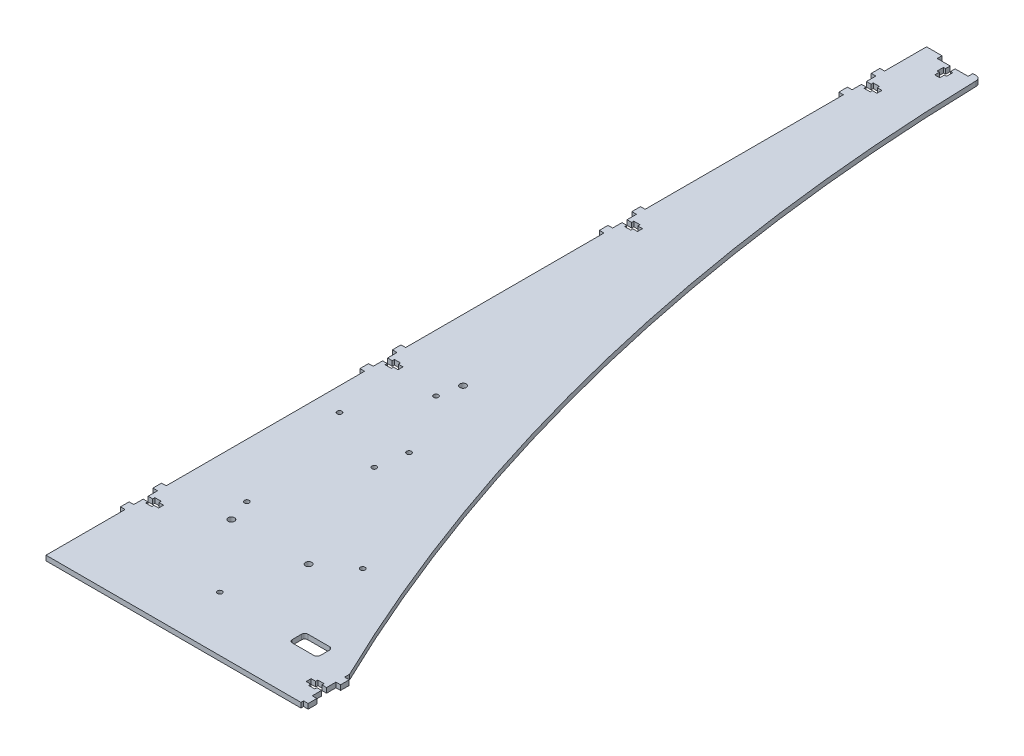
from build123d import *

# Parameters (mm, degrees)
SALIENTE_EXTRUIR1_DEPTH = 3.2
CROQUIS3_R              = 2.05
CORTAR_EXTRUIR2_DEPTH   = 3.2
CORTAR_EXTRUIR3_DEPTH   = 3.2
CORTAR_EXTRUIR4_DEPTH   = 3.2
REDONDEO1_R             = 3
CROQUIS6_R              = 1.55
CORTAR_EXTRUIR5_DEPTH   = 3.2
CROQUIS7_W              = 3
CROQUIS7_H              = 0.2
CORTAR_EXTRUIR6_DEPTH   = 3.2


with BuildPart() as part:
    # Croquis1 → Saliente-Extruir1 (new body)
    with BuildSketch(Plane(origin=(0, 0, 0), x_dir=(1, 0, 0), z_dir=(0, 1, 0))):
        Polygon((7, 66.1), (10, 66.1), (10, 62.9), (7, 62.9), (7, 61.5), (3, 61.5), (3, 62.9), (0, 62.9), (0, 57), (-3, 57), (-3, 51), (0, 51), (0, 0), (165, 0), (165, 1.5), (168, 1.5), (168, 7.5), (165, 7.5), (165, 13.4), (162, 13.4), (162, 12), (158, 12), (158, 13.4), (155, 13.4), (155, 16.6), (158, 16.6), (158, 18), (162, 18), (162, 16.6), (165, 16.6), (165, 22.5), (168, 22.5), (168, 28.5), (165, 28.5), (165, 570), (30, 570), (30, 566.9), (21.6, 566.9), (21.6, 563.9), (23, 563.9), (23, 559.9), (21.6, 559.9), (21.6, 556.9), (18.4, 556.9), (18.4, 559.9), (17, 559.9), (17, 563.9), (18.4, 563.9), (18.4, 566.9), (10, 566.9), (10, 570), (0, 570), (0, 543), (-3, 543), (-3, 537), (0, 537), (0, 531.1), (3, 531.1), (3, 532.5), (7, 532.5), (7, 531.1), (10, 531.1), (10, 527.9), (7, 527.9), (7, 526.5), (3, 526.5), (3, 527.9), (0, 527.9), (0, 522), (-3, 522), (-3, 516), (0, 516), (0, 388), (-3, 388), (-3, 382), (0, 382), (0, 376.1), (3, 376.1), (3, 377.5), (7, 377.5), (7, 376.1), (10, 376.1), (10, 372.9), (7, 372.9), (7, 371.5), (3, 371.5), (3, 372.9), (0, 372.9), (0, 367), (-3, 367), (-3, 361), (0, 361), (0, 233), (-3, 233), (-3, 227), (0, 227), (0, 221.1), (3, 221.1), (3, 222.5), (7, 222.5), (7, 221.1), (10, 221.1), (10, 217.9), (7, 217.9), (7, 216.5), (3, 216.5), (3, 217.9), (0, 217.9), (0, 212), (-3, 212), (-3, 206), (0, 206), (0, 78), (-3, 78), (-3, 72), (0, 72), (0, 66.1), (3, 66.1), (3, 67.5), (7, 67.5), align=None)
    extrude(amount=SALIENTE_EXTRUIR1_DEPTH)

    # Croquis3 → Cortar-Extruir2 (cut)
    with BuildSketch(Plane(origin=(0, 3.2, 0), x_dir=(1, 0, 0), z_dir=(0, 1, 0))):
        with Locations((40, 80)):
            Circle(CROQUIS3_R)
        with Locations((90, 80)):
            Circle(CROQUIS3_R)
        with Locations((40, 230)):
            Circle(CROQUIS3_R)
    extrude(amount=-CORTAR_EXTRUIR2_DEPTH, mode=Mode.SUBTRACT)

    # Croquis4 → Cortar-Extruir3 (cut)
    with BuildSketch(Plane.XZ):
        with BuildLine():
            Line((143, -30.5), (129, -30.5))
            ThreePointArc((129, -30.5), (127.585786438, -31.085786438), (127, -32.5))
            Line((127, -32.5), (127, -38.5))
            ThreePointArc((127, -38.5), (127.585786438, -39.914213562), (129, -40.5))
            Line((129, -40.5), (143, -40.5))
            ThreePointArc((143, -40.5), (144.414213562, -39.914213562), (145, -38.5))
            Line((145, -38.5), (145, -32.5))
            ThreePointArc((145, -32.5), (144.414213562, -31.085786438), (143, -30.5))
        make_face()
    extrude(amount=-CORTAR_EXTRUIR3_DEPTH, mode=Mode.SUBTRACT)

    # Croquis5 → Cortar-Extruir4 (cut)
    with BuildSketch(Plane.XZ):
        with BuildLine():
            Line((35, -570), (165, -570))
            Line((165, -570), (165, -31.5))
            ThreePointArc((165, -31.5), (70.982951471, -293.744955787), (35, -570))
        make_face()
    extrude(amount=-CORTAR_EXTRUIR4_DEPTH, mode=Mode.SUBTRACT)

    # Redondeo1
    redondeo1_edges = [part.edges().sort_by_distance(p)[0] for p in [
        (35, 1.6, -570),
    ]]
    fillet(redondeo1_edges, radius=REDONDEO1_R)

    # Croquis6 → Cortar-Extruir5 (cut)
    with BuildSketch(Plane.XZ):
        with Locations((110, -95)):
            Circle(CROQUIS6_R)
        with Locations((35, -95)):
            Circle(CROQUIS6_R)
        with Locations((60, -175)):
            Circle(CROQUIS6_R)
        with Locations((15, -175)):
            Circle(CROQUIS6_R)
        with Locations((77, -35.5)):
            Circle(CROQUIS6_R)
        with Locations((37, -215.5)):
            Circle(CROQUIS6_R)
        with Locations((57, -155.5)):
            Circle(CROQUIS6_R)
    extrude(amount=-CORTAR_EXTRUIR5_DEPTH, mode=Mode.SUBTRACT)

    # Croquis7 → Cortar-Extruir6 (cut)
    with BuildSketch(Plane.XZ):
        with Locations((-1.5, -542.9)):
            Rectangle(CROQUIS7_W, CROQUIS7_H)
        with Locations((-1.5, -537.1)):
            Rectangle(CROQUIS7_W, CROQUIS7_H)
        with Locations((-1.5, -521.9)):
            Rectangle(CROQUIS7_W, CROQUIS7_H)
        with Locations((-1.5, -516.1)):
            Rectangle(CROQUIS7_W, CROQUIS7_H)
        with Locations((-1.5, -387.9)):
            Rectangle(CROQUIS7_W, CROQUIS7_H)
        with Locations((-1.5, -382.1)):
            Rectangle(CROQUIS7_W, CROQUIS7_H)
        with Locations((-1.5, -366.9)):
            Rectangle(CROQUIS7_W, CROQUIS7_H)
        with Locations((-1.5, -361.1)):
            Rectangle(CROQUIS7_W, CROQUIS7_H)
        with Locations((-1.5, -232.9)):
            Rectangle(CROQUIS7_W, CROQUIS7_H)
        with Locations((-1.5, -227.1)):
            Rectangle(CROQUIS7_W, CROQUIS7_H)
        with Locations((-1.5, -211.9)):
            Rectangle(CROQUIS7_W, CROQUIS7_H)
        with Locations((-1.5, -206.1)):
            Rectangle(CROQUIS7_W, CROQUIS7_H)
        with Locations((-1.5, -77.9)):
            Rectangle(CROQUIS7_W, CROQUIS7_H)
        with Locations((-1.5, -72.1)):
            Rectangle(CROQUIS7_W, CROQUIS7_H)
        with Locations((-1.5, -51.1)):
            Rectangle(CROQUIS7_W, CROQUIS7_H)
        with Locations((-1.5, -56.9)):
            Rectangle(CROQUIS7_W, CROQUIS7_H)
        with Locations((166.5, -28.4)):
            Rectangle(CROQUIS7_W, CROQUIS7_H)
        with Locations((166.5, -22.6)):
            Rectangle(CROQUIS7_W, CROQUIS7_H)
        with Locations((166.5, -7.4)):
            Rectangle(CROQUIS7_W, CROQUIS7_H)
        with Locations((166.5, -1.6)):
            Rectangle(CROQUIS7_W, CROQUIS7_H)
    extrude(amount=-CORTAR_EXTRUIR6_DEPTH, mode=Mode.SUBTRACT)


solid = part.part
